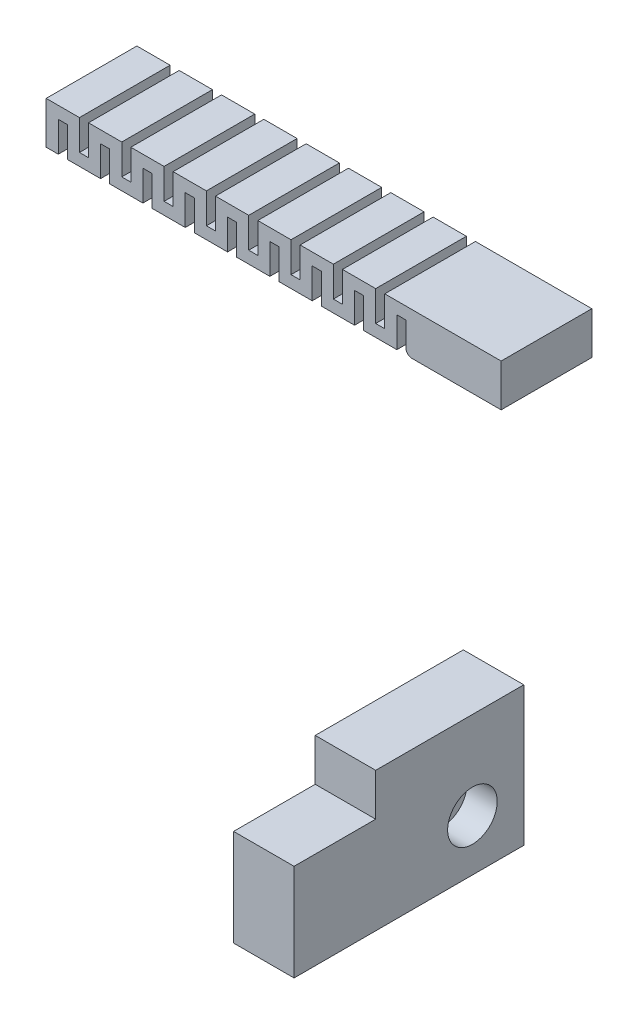
from build123d import *

# Parameters (mm, degrees)
BOSS_EXTRUDE1_DEPTH = 62.5
SKETCH2_W           = 31.5
SKETCH2_H           = 7
BOSS_EXTRUDE2_DEPTH = 20
SKETCH3_W           = 15
SKETCH3_H           = 7
BOSS_EXTRUDE3_DEPTH = 19
SKETCH4_W           = 15
SKETCH4_H           = 15
BOSS_EXTRUDE4_DEPTH = 10
SKETCH5_R           = 3.71375
CUT_EXTRUDE1_DEPTH  = 7
FILLET1_R           = 1
FILLET2_R           = 1
SKETCH7_R           = 4.1
BOSS_EXTRUDE5_DEPTH = 10
SKETCH7_3_R         = 4.1
SKETCH7_3_R_2       = 2.55
BOSS_EXTRUDE6_DEPTH = 5
SKETCH8_W           = 8
SKETCH8_H           = 50
BOSS_EXTRUDE7_DEPTH = 7
SKETCH9_W           = 3
SKETCH9_H           = 40
CUT_EXTRUDE2_DEPTH  = 10
CUT_EXTRUDE3_DEPTH  = 134.333463542


with BuildPart() as part:
    # Sketch1 → Boss-Extrude1 (new body)
    with BuildSketch(Plane.XY):
        Polygon((13.75, -3.5), (-13.75, -3.5), (-15.75, -3.5), (-15.75, 1.5), (-17.25, 1.5), (-17.25, -3.5), (-22.75, -3.5), (-22.75, 1.5), (-24.25, 1.5), (-24.25, -3.5), (-29.75, -3.5), (-29.75, 1.5), (-31.25, 1.5), (-31.25, -3.5), (-36.75, -3.5), (-36.75, 1.5), (-38.25, 1.5), (-38.25, -3.5), (-43.75, -3.5), (-43.75, 1.5), (-45.25, 1.5), (-45.25, -3.5), (-50.75, -3.5), (-50.75, 1.5), (-52.25, 1.5), (-52.25, -3.5), (-57.75, -3.5), (-57.75, 1.5), (-59.25, 1.5), (-59.25, -3.5), (-64.75, -3.5), (-64.75, 1.5), (-66.25, 1.5), (-66.25, -3.5), (-71.75, -3.5), (-71.75, 1.5), (-73.25, 1.5), (-73.25, -3.5), (-75.25, -3.5), (-75.25, 3.5), (-69.75, 3.5), (-69.75, -1.5), (-68.25, -1.5), (-68.25, 3.5), (-62.75, 3.5), (-62.75, -1.5), (-61.25, -1.5), (-61.25, 3.5), (-55.75, 3.5), (-55.75, -1.5), (-54.25, -1.5), (-54.25, 3.5), (-48.75, 3.5), (-48.75, -1.5), (-47.25, -1.5), (-47.25, 3.5), (-41.75, 3.5), (-41.75, -1.5), (-40.25, -1.5), (-40.25, 3.5), (-34.75, 3.5), (-34.75, -1.5), (-33.25, -1.5), (-33.25, 3.5), (-27.75, 3.5), (-27.75, -1.5), (-26.25, -1.5), (-26.25, 3.5), (-20.75, 3.5), (-20.75, -1.5), (-19.25, -1.5), (-19.25, 3.5), (-13.75, 3.5), (13.75, 3.5), (19.25, 3.5), (19.25, -1.5), (20.75, -1.5), (20.75, 3.5), (26.25, 3.5), (26.25, -1.5), (27.75, -1.5), (27.75, 3.5), (33.25, 3.5), (33.25, -1.5), (34.75, -1.5), (34.75, 3.5), (40.25, 3.5), (40.25, -1.5), (41.75, -1.5), (41.75, 3.5), (47.25, 3.5), (47.25, -1.5), (48.75, -1.5), (48.75, 3.5), (54.25, 3.5), (54.25, -1.5), (55.75, -1.5), (55.75, 3.5), (61.25, 3.5), (61.25, -1.5), (62.75, -1.5), (62.75, 3.5), (68.25, 3.5), (68.25, -1.5), (69.75, -1.5), (69.75, 3.5), (75.25, 3.5), (75.25, -3.5), (73.25, -3.5), (73.25, 1.5), (71.75, 1.5), (71.75, -3.5), (66.25, -3.5), (66.25, 1.5), (64.75, 1.5), (64.75, -3.5), (59.25, -3.5), (59.25, 1.5), (57.75, 1.5), (57.75, -3.5), (52.25, -3.5), (52.25, 1.5), (50.75, 1.5), (50.75, -3.5), (45.25, -3.5), (45.25, 1.5), (43.75, 1.5), (43.75, -3.5), (38.25, -3.5), (38.25, 1.5), (36.75, 1.5), (36.75, -3.5), (31.25, -3.5), (31.25, 1.5), (29.75, 1.5), (29.75, -3.5), (24.25, -3.5), (24.25, 1.5), (22.75, 1.5), (22.75, -3.5), (17.25, -3.5), (17.25, 1.5), (15.75, 1.5), (15.75, -3.5), align=None)
    extrude(amount=BOSS_EXTRUDE1_DEPTH)

    # Sketch2 → Boss-Extrude2 (add)
    with BuildSketch(Plane.XY.offset(62.5)):
        Rectangle(SKETCH2_W, SKETCH2_H)
    extrude(amount=BOSS_EXTRUDE2_DEPTH)

    # Sketch3 → Boss-Extrude3 (add)
    with BuildSketch(Plane(origin=(15.75, 0, 0), x_dir=(0, 0, -1), z_dir=(1, 0, 0))):
        with Locations((-75, 0)):
            Rectangle(SKETCH3_W, SKETCH3_H)
    boss_extrude3 = extrude(amount=BOSS_EXTRUDE3_DEPTH)

    # Mirror1: Boss-Extrude3 across plane
    add(boss_extrude3.mirror(Plane(origin=(0, 0, 0), x_dir=(0, 0, 1), z_dir=(1, 0, 0))))

    # Sketch4 → Boss-Extrude4 (add)
    with BuildSketch(Plane(origin=(34.75, 0, 0), x_dir=(0, 0, -1), z_dir=(1, 0, 0))):
        with Locations((-75, -4)):
            Rectangle(SKETCH4_W, SKETCH4_H)
    boss_extrude4 = extrude(amount=BOSS_EXTRUDE4_DEPTH)

    # Mirror2: Boss-Extrude4 across plane
    add(boss_extrude4.mirror(Plane(origin=(0, 0, 0), x_dir=(0, 0, 1), z_dir=(1, 0, 0))))

    # Sketch5 → Cut-Extrude1 (cut)
    with BuildSketch(Plane(origin=(44.75, 0, 0), x_dir=(0, 0, -1), z_dir=(1, 0, 0))):
        with Locations((-75, -4)):
            Circle(SKETCH5_R)
    cut_extrude1 = extrude(amount=-CUT_EXTRUDE1_DEPTH, mode=Mode.SUBTRACT)

    # Mirror3: Cut-Extrude1 across plane
    add(cut_extrude1.mirror(Plane(origin=(0, 0, 0), x_dir=(0, 0, 1), z_dir=(1, 0, 0))), mode=Mode.SUBTRACT)

    # Fillet1
    fillet1_edges = [part.edges().sort_by_distance(p)[0] for p in [
        (-34.75, -7.5, 82.5),
        (-25.25, -3.5, 67.5),
        (0, -3.5, 82.5),
        (25.25, -3.5, 67.5),
        (34.75, -11.5, 75),
        (-34.75, -11.5, 75),
        (-34.75, -7.5, 67.5),
        (34.75, -7.5, 82.5),
        (34.75, -7.5, 67.5),
        (-44.75, 3.5, 75),
        (34.75, -3.5, 75),
        (-34.75, -3.5, 75),
        (44.75, -4, 82.5),
        (44.75, -11.5, 75),
        (44.75, 3.5, 75),
        (44.75, -4, 67.5),
        (39.75, -11.5, 67.5),
        (-39.75, -11.5, 67.5),
        (-44.75, -11.5, 75),
        (-44.75, -4, 67.5),
        (-44.75, -4, 82.5),
        (0, 3.5, 82.5),
    ]]
    fillet(fillet1_edges, radius=FILLET1_R)

    # Fillet2
    fillet2_edges = [part.edges().sort_by_distance(p)[0] for p in [
        (15.75, -3.5, 34.25),
        (-15.75, -3.5, 34.25),
    ]]
    fillet(fillet2_edges, radius=FILLET2_R)

    # Sketch8 → Boss-Extrude7 (add)
    with BuildSketch(Plane(origin=(0, 3.5, 0), x_dir=(1, 0, 0), z_dir=(0, 1, 0))):
        with Locations((77.25, -31.25)):
            Rectangle(SKETCH8_W, SKETCH8_H)
    extrude(amount=-BOSS_EXTRUDE7_DEPTH)

    # Sketch9 → Cut-Extrude2 (cut)
    with BuildSketch(Plane(origin=(0, 3.5, 0), x_dir=(1, 0, 0), z_dir=(0, 1, 0))):
        with Locations((77.25, -31.25)):
            Rectangle(SKETCH9_W, SKETCH9_H)
    extrude(amount=-CUT_EXTRUDE2_DEPTH, mode=Mode.SUBTRACT)

    # Sketch10 → Cut-Extrude3 (cut, through all)
    with BuildSketch(Plane(origin=(0, 3.5, 0), x_dir=(1, 0, 0), z_dir=(0, 1, 0))):
        Polygon((0, 0), (86.365697076, 0), (86.365697076, -92.937569977), (-81.175072776, -92.937569977), (-81.175072776, -15), (0, -15), align=None)
    extrude(amount=-CUT_EXTRUDE3_DEPTH, mode=Mode.SUBTRACT)


with BuildPart() as body_2:
    # Sketch7 → Boss-Extrude5 (new body)
    with BuildSketch(Plane(origin=(45.25, 0, 0), x_dir=(0, 0, -1), z_dir=(1, 0, 0))):
        Polygon((-91, -12.5), (-66.5, -12.5), (-66.5, 10.5), (-91, 10.5), (-91, 3.5), (-104.5, 3.5), (-104.5, -12.5), align=None)
        with Locations((-75, -4)):
            Circle(SKETCH7_R, mode=Mode.SUBTRACT)
    extrude(amount=BOSS_EXTRUDE5_DEPTH)

    # Sketch7_3 → Boss-Extrude6 (add)
    with BuildSketch(Plane(origin=(45.25, 0, 0), x_dir=(0, 0, -1), z_dir=(1, 0, 0))):
        with Locations((-75, -4)):
            Circle(SKETCH7_3_R)
        with Locations((-75, -4)):
            Circle(SKETCH7_3_R_2, mode=Mode.SUBTRACT)
    extrude(amount=BOSS_EXTRUDE6_DEPTH)


solid = Compound([part.part, body_2.part])
